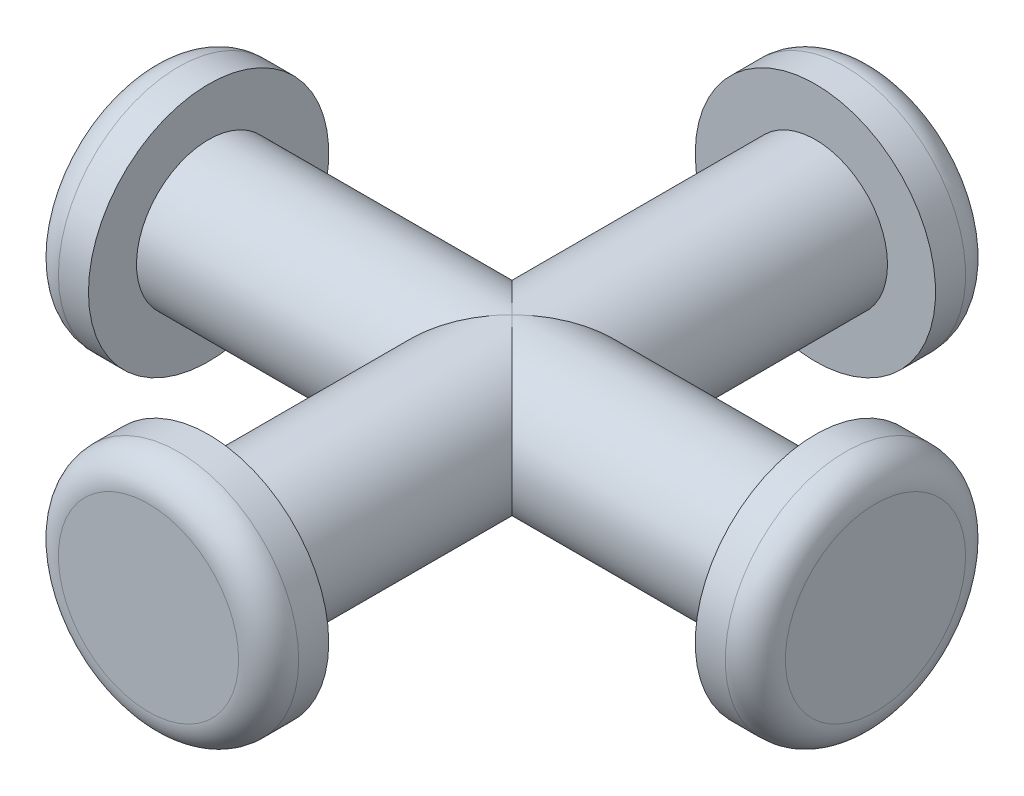
from build123d import *

# Parameters (mm, degrees)
ESQUISSE1_R        = 2.4
BOSS_EXTRU_1_DEPTH = 10.1
ESQUISSE3_R        = 2.4
BOSS_EXTRU_2_DEPTH = 10.1
ESQUISSE4_R        = 4
BOSS_EXTRU_3_DEPTH = 2
ESQUISSE5_R        = 4
BOSS_EXTRU_4_DEPTH = 2
ESQUISSE6_R        = 4
BOSS_EXTRU_5_DEPTH = 2
ESQUISSE7_R        = 4
BOSS_EXTRU_6_DEPTH = 2
CONG_1_R           = 1


with BuildPart() as part:
    # Esquisse1 → Boss.-Extru.1 (new body, symmetric)
    with BuildSketch(Plane.XY):
        Circle(ESQUISSE1_R)
    extrude(amount=BOSS_EXTRU_1_DEPTH, both=True)

    # Esquisse3 → Boss.-Extru.2 (add, symmetric)
    with BuildSketch(Plane(origin=(0, 0, 0), x_dir=(0, 0, -1), z_dir=(1, 0, 0))):
        with Locations(Location((0, 0, 0), (0, 0, 270))):  # turned: the seam where the file's is
            Circle(ESQUISSE3_R)
    extrude(amount=BOSS_EXTRU_2_DEPTH, both=True)

    # Esquisse4 → Boss.-Extru.3 (add)
    with BuildSketch(Plane(origin=(10.1, 0, 0), x_dir=(0, 0, -1), z_dir=(1, 0, 0))):
        Circle(ESQUISSE4_R)
    extrude(amount=BOSS_EXTRU_3_DEPTH)

    # Esquisse5 → Boss.-Extru.4 (add)
    with BuildSketch(Plane.ZY.offset(10.1)):
        with Locations(Location((0, 0, 0), (0, 0, 180))):  # turned: the seam where the file's is
            Circle(ESQUISSE5_R)
    extrude(amount=BOSS_EXTRU_4_DEPTH)

    # Esquisse6 → Boss.-Extru.5 (add)
    with BuildSketch(Plane.XY.offset(10.1)):
        Circle(ESQUISSE6_R)
    extrude(amount=BOSS_EXTRU_5_DEPTH)

    # Esquisse7 → Boss.-Extru.6 (add)
    with BuildSketch(Plane(origin=(0, 0, -10.1), x_dir=(-1, 0, 0), z_dir=(0, 0, -1))):
        with Locations(Location((0, 0, 0), (0, 0, 180))):  # turned: the seam where the file's is
            Circle(ESQUISSE7_R)
    extrude(amount=BOSS_EXTRU_6_DEPTH)

    # Congé1
    cong_1_edges = [part.edges().sort_by_distance(p)[0] for p in [
        (12.1, 0, 4),
        (-12.1, 0, 4),
        (-4, 0, 12.1),
        (-4, 0, -12.1),
    ]]
    fillet(cong_1_edges, radius=CONG_1_R)


solid = part.part
